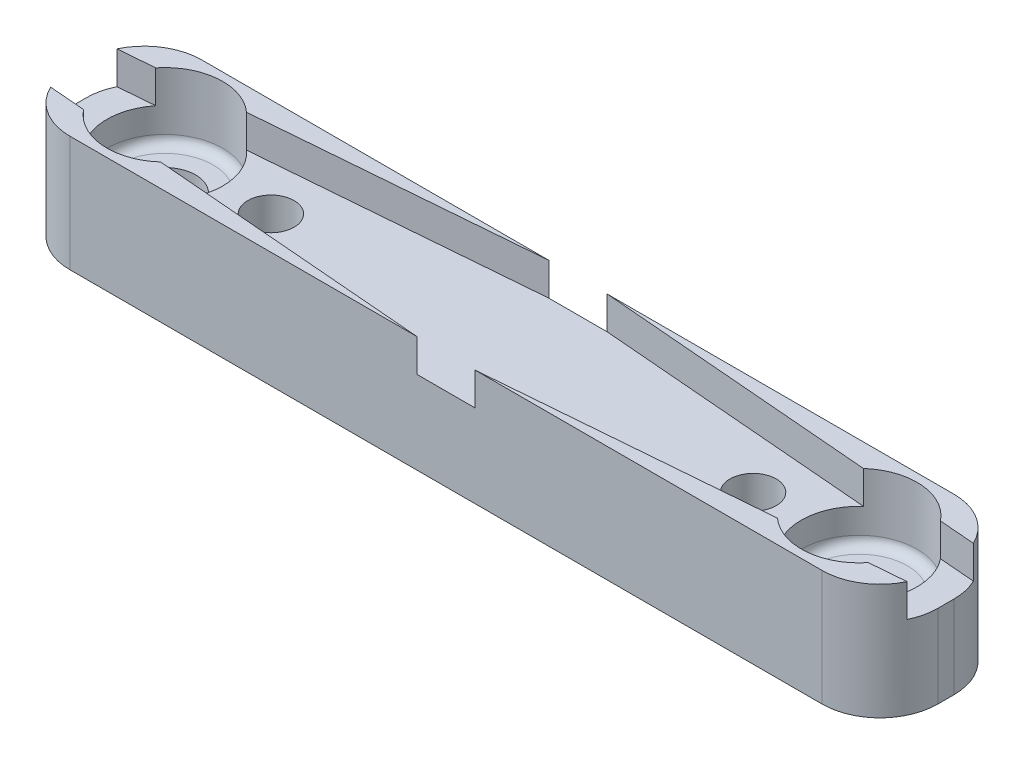
from build123d import *

# Parameters (mm, degrees)
SKETCH_2_R               = 1.2
SKETCH_2_R_2             = 1.6
EXTRUDE_2_DEPTH          = 6
SKETCH_3_R               = 3
CUT_EXTRUDE_1_DEPTH      = 1
FILLET_2_R               = 3
CUT_EXTRUDE_2_DEPTH      = 1.7
CUT_EXTRUDE_3_DEPTH      = 25.23816287
CUT_EXTRUDE_3_DEPTH_BACK = 1.8
SKETCH_5_R               = 3
FILLET_3_R               = 0.5


with BuildPart() as part:
    # 草图2 → 凸台-拉伸2 (new body)
    with BuildSketch(Plane(origin=(0, 0, 4.5), x_dir=(1, 0, 0), z_dir=(0, 1, 0))):
        Polygon((22.5, -3.42139756), (22.5, 3.421397553), (3.906515802, 3.421397553), (-3.906515802, 3.421397553), (-22.5, 3.421397553), (-22.5, -3.42139756), (-3.906515802, -3.42139756), (3.906515802, -3.42139756), align=None)
        with Locations((-12.5, -3e-09)):
            Circle(SKETCH_2_R, mode=Mode.SUBTRACT)
        with Locations((12.5, -3e-09)):
            Circle(SKETCH_2_R, mode=Mode.SUBTRACT)
        with Locations((-18, -3e-09)):
            Circle(SKETCH_2_R_2, mode=Mode.SUBTRACT)
        with Locations((18, -3e-09)):
            Circle(SKETCH_2_R_2, mode=Mode.SUBTRACT)
    extrude(amount=EXTRUDE_2_DEPTH)

    # 草图3 → 切除-拉伸1 (cut)
    with BuildSketch(Plane(origin=(0, 0, 0), x_dir=(-1, 0, 0), z_dir=(0, -1, 0))):
        with Locations((-12.5, -4.500000003)):
            Circle(SKETCH_3_R)
        with Locations((12.5, -4.500000003)):
            Circle(SKETCH_3_R)
    extrude(amount=-CUT_EXTRUDE_1_DEPTH, mode=Mode.SUBTRACT)

    # 圆角2
    fillet_2_edges = [part.edges().sort_by_distance(p)[0] for p in [
        (22.5, 3, 1.078602447),
        (22.5, 3, 7.92139756),
        (-22.5, 3, 7.92139756),
        (-22.5, 3, 1.078602447),
    ]]
    fillet(fillet_2_edges, radius=FILLET_2_R)

    # 草图4 → 切除-拉伸2 (cut)
    with BuildSketch(Plane(origin=(0, 6, 0), x_dir=(1, 0, 0), z_dir=(0, 1, 0))):
        Polygon((43.079074711, -4.500000003), (0, -8.046158962), (-43.079074711, -4.500000003), (0, -0.953841045), align=None)
    extrude(amount=-CUT_EXTRUDE_2_DEPTH, mode=Mode.SUBTRACT)

    # 草图5 → 切除-拉伸3 (cut, two sides: drawn at the far end of the back side and taken through both)
    with BuildSketch(Plane(origin=(0, 4.3, 0), x_dir=(1, 0, 0), z_dir=(0, 1, 0)).offset(-CUT_EXTRUDE_3_DEPTH_BACK)):
        with Locations((-18, -4.500000003)):
            Circle(SKETCH_5_R)
        with Locations((18, -4.500000003)):
            Circle(SKETCH_5_R)
    extrude(amount=CUT_EXTRUDE_3_DEPTH + CUT_EXTRUDE_3_DEPTH_BACK, mode=Mode.SUBTRACT)

    # 圆角3
    fillet_3_edges = [part.edges().sort_by_distance(p)[0] for p in [
        (15, 2.5, 4.500000003),
        (-21, 2.5, 4.500000003),
        (-9.5, 1, 4.500000003),
        (15.5, 1, 4.500000003),
    ]]
    fillet(fillet_3_edges, radius=FILLET_3_R)


solid = part.part
